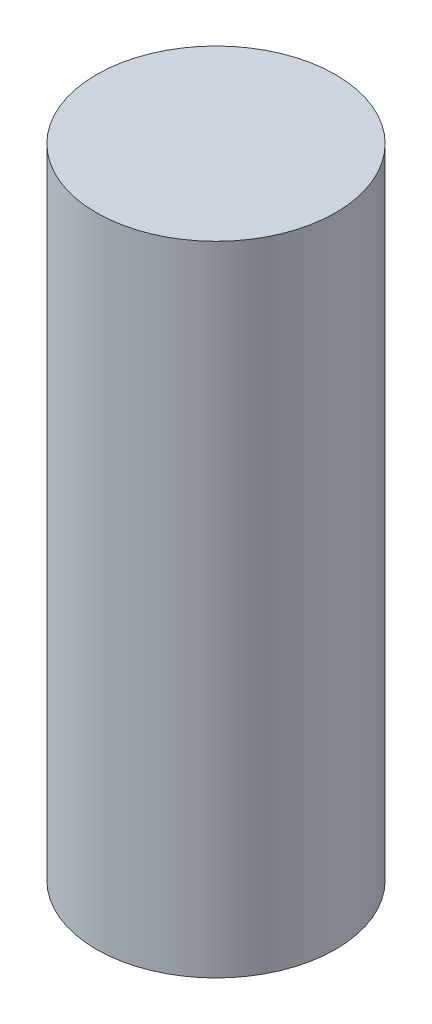
from build123d import *

# Parameters (mm, degrees)
SKETCH1_R           = 9.525
BOSS_EXTRUDE1_DEPTH = 50.8


with BuildPart() as part:
    # Sketch1 → Boss-Extrude1 (new body)
    with BuildSketch(Plane(origin=(0, 0, 0), x_dir=(1, 0, 0), z_dir=(0, 1, 0))):
        Circle(SKETCH1_R)
    extrude(amount=BOSS_EXTRUDE1_DEPTH)


solid = part.part
